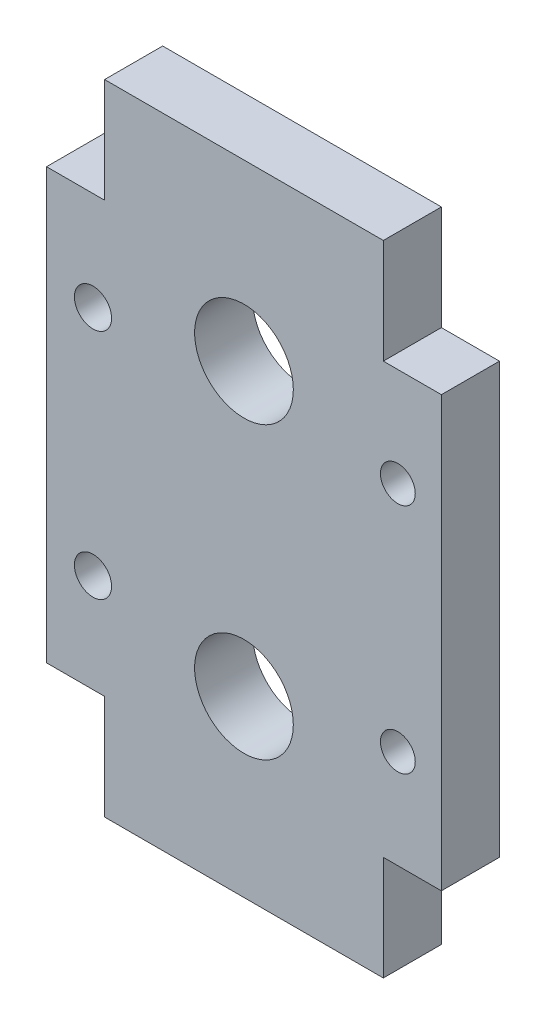
from build123d import *

# Parameters (mm, degrees)
SKETCH1_R           = 1.5
SKETCH1_R_2         = 4.25
SKETCH1_R_3         = 5
SKETCH1_R_4         = 1
BOSS_EXTRUDE2_DEPTH = 5
SKETCH2_W           = 0.5
SKETCH2_H           = 37
BOSS_EXTRUDE3_DEPTH = 5
CUT_EXTRUDE1_DEPTH  = 10
BOSS_EXTRUDE4_DEPTH = 5
SKETCH5_R           = 1.6
CUT_EXTRUDE2_DEPTH  = 10
BOSS_EXTRUDE5_DEPTH = 5
SKETCH7_R           = 1
BOSS_EXTRUDE6_DEPTH = 5
SKETCH8_W           = 5
SKETCH8_H           = 37
CUT_EXTRUDE3_DEPTH  = 33


with BuildPart() as part:
    # Sketch1 → Boss-Extrude2 (new body)
    with BuildSketch(Plane.XY):
        with BuildLine():
            Line((45.25091594, -25.207708346), (50.00091594, -20.457708346))
            Line((50.00091594, -20.457708346), (50.00091594, 24.688738263))
            Line((50.00091594, 24.688738263), (45.147362549, 29.542291654))
            Line((45.147362549, 29.542291654), (26.35446933, 29.542291654))
            Line((26.35446933, 29.542291654), (21.25091594, 24.438738263))
            Line((21.25091594, 24.438738263), (21.25091594, 18.042291654))
            Line((21.25091594, 18.042291654), (20.408095363, 18.042291654))
            Line((20.408095363, 18.042291654), (16.70086026, 18.042291654))
            ThreePointArc((16.70086026, 18.042291654), (12.892426636, 17.542145454), (9.3422674, 16.075624987))
            ThreePointArc((9.3422674, 16.075624987), (2.182128173, 13.100539865), (-5.49908406, 12.043324729))
            Line((-5.49908406, 12.043324729), (-5.49908406, 12.039085999))
            ThreePointArc((-5.49908406, 12.039085999), (-15.49908406, 2.292291654), (-5.49908406, -7.454502691))
            Line((-5.49908406, -7.454502691), (-5.49908406, -7.458741422))
            ThreePointArc((-5.49908406, -7.458741422), (2.182128173, -8.515956557), (9.3422674, -11.491041679))
            ThreePointArc((9.3422674, -11.491041679), (12.892426636, -12.957562146), (16.70086026, -13.457708346))
            Line((16.70086026, -13.457708346), (20.408095363, -13.457708346))
            Line((20.408095363, -13.457708346), (21.25091594, -13.457708346))
            Line((21.25091594, -13.457708346), (21.25091594, -20.207708346))
            Line((21.25091594, -20.207708346), (26.25091594, -25.207708346))
            Line((26.25091594, -25.207708346), (45.25091594, -25.207708346))
        make_face()
        with Locations((46.75091594, -7.707708346)):
            Circle(SKETCH1_R, mode=Mode.SUBTRACT)
        with Locations((46.75091594, 12.292291654)):
            Circle(SKETCH1_R, mode=Mode.SUBTRACT)
        with Locations((33.50091594, 14.792291654)):
            Circle(SKETCH1_R_2, mode=Mode.SUBTRACT)
        with Locations((33.50091594, -10.207708346)):
            Circle(SKETCH1_R_2, mode=Mode.SUBTRACT)
        with Locations((19.25091594, 12.292291654)):
            Circle(SKETCH1_R, mode=Mode.SUBTRACT)
        with Locations((19.25091594, -7.707708346)):
            Circle(SKETCH1_R, mode=Mode.SUBTRACT)
        with Locations((-5.74908406, 2.292291654)):
            Circle(SKETCH1_R_3, mode=Mode.SUBTRACT)
        with Locations((1.25091594, 2.354746229)):
            Circle(SKETCH1_R_4, mode=Mode.SUBTRACT)
        with Locations((-5.686629485, -4.707708346)):
            Circle(SKETCH1_R_4, mode=Mode.SUBTRACT)
        with Locations((-12.74908406, 2.229837079)):
            Circle(SKETCH1_R_4, mode=Mode.SUBTRACT)
        with Locations((-5.811538636, 9.292291654)):
            Circle(SKETCH1_R_4, mode=Mode.SUBTRACT)
    extrude(amount=BOSS_EXTRUDE2_DEPTH)

    # Sketch2 → Boss-Extrude3 (add)
    with BuildSketch(Plane(origin=(0, 0, 0), x_dir=(-1, 0, 0), z_dir=(0, 0, -1))):
        Polygon((-26.25091594, -25.207708346), (-21.50091594, -25.207708346), (-21.50091594, -20.457708346), align=None)
        Polygon((-45.25091594, -25.207708346), (-45.50091594, -25.207708346), (-45.50091594, -24.957708346), align=None)
        Polygon((-45.50091594, 29.188738263), (-45.50091594, 29.792291654), (-21.50091594, 29.792291654), (-21.50091594, 24.688738263), (-26.35446933, 29.542291654), (-45.147362549, 29.542291654), align=None)
        with Locations((-50.25091594, 2.292291654)):
            Rectangle(SKETCH2_W, SKETCH2_H)
    extrude(amount=-BOSS_EXTRUDE3_DEPTH)

    # Sketch3 → Cut-Extrude1 (cut)
    with BuildSketch(Plane(origin=(0, 0, 0), x_dir=(-1, 0, 0), z_dir=(0, 0, -1))):
        Polygon((-50.00091594, -16.207708346), (-45.50091594, -16.207708346), (-45.50091594, -25.207708346), (-50.00091594, -20.457708346), align=None)
        Polygon((-50.50091594, 20.792291654), (-45.50091594, 20.792291654), (-45.50091594, 29.188738263), (-50.00091594, 24.688738263), align=None)
        Polygon((-21.50091594, -16.207708346), (-21.50091594, -20.457708346), (-21.25091594, -20.207708346), (-21.25091594, -16.207708346), align=None)
        Polygon((-21.50091594, 20.792291654), (-21.25091594, 20.792291654), (-21.25091594, 24.438738263), (-21.50091594, 24.688738263), align=None)
    extrude(amount=-CUT_EXTRUDE1_DEPTH, mode=Mode.SUBTRACT)

    # Sketch4 → Boss-Extrude4 (add)
    with BuildSketch(Plane(origin=(0, 0, 0), x_dir=(-1, 0, 0), z_dir=(0, 0, -1))):
        with BuildLine():
            Line((-21.25091594, 20.792291654), (-16.50091594, 20.792291654))
            Line((-16.50091594, 20.792291654), (-16.50091594, 18.040936414))
            ThreePointArc((-16.50091594, 18.040936414), (-16.600885803, 18.04195284), (-16.70086026, 18.042291654))
            Line((-16.70086026, 18.042291654), (-21.25091594, 18.042291654))
            Line((-21.25091594, 18.042291654), (-21.25091594, 20.792291654))
        make_face()
        with BuildLine():
            Line((-16.50091594, -13.456353106), (-16.50091594, -16.207708346))
            Line((-16.50091594, -16.207708346), (-21.25091594, -16.207708346))
            Line((-21.25091594, -16.207708346), (-21.25091594, -13.457708346))
            Line((-21.25091594, -13.457708346), (-16.70086026, -13.457708346))
            ThreePointArc((-16.70086026, -13.457708346), (-16.600885803, -13.457369532), (-16.50091594, -13.456353106))
        make_face()
    extrude(amount=-BOSS_EXTRUDE4_DEPTH)

    # Sketch5 → Cut-Extrude2 (cut)
    with BuildSketch(Plane.XY.offset(5)):
        with Locations((20.50091594, -7.707708346)):
            Circle(SKETCH5_R)
        with Locations((20.50091594, 12.292291654)):
            Circle(SKETCH5_R)
    extrude(amount=-CUT_EXTRUDE2_DEPTH, mode=Mode.SUBTRACT)

    # Sketch6 → Boss-Extrude5 (add)
    with BuildSketch(Plane.XY.offset(5)):
        with BuildLine():
            ThreePointArc((19.75191594, -6.293848735), (18.90091594, -7.707708346), (19.75191594, -9.121567957))
            ThreePointArc((19.75191594, -9.121567957), (17.75091594, -7.707708346), (19.75191594, -6.293848735))
        make_face()
        with BuildLine():
            ThreePointArc((19.75191594, 13.706151265), (18.90091594, 12.292291654), (19.75191594, 10.878432043))
            ThreePointArc((19.75191594, 10.878432043), (17.75091594, 12.292291654), (19.75191594, 13.706151265))
        make_face()
    extrude(amount=-BOSS_EXTRUDE5_DEPTH)

    # Sketch7 → Boss-Extrude6 (add)
    with BuildSketch(Plane(origin=(0, 0, 0), x_dir=(-1, 0, 0), z_dir=(0, 0, -1))):
        with Locations((-1.25091594, 2.354746229)):
            Circle(SKETCH7_R)
        with Locations((12.74908406, 2.229837079)):
            Circle(SKETCH7_R)
    extrude(amount=-BOSS_EXTRUDE6_DEPTH)

    # Sketch8 → Cut-Extrude3 (cut, through all)
    with BuildSketch(Plane.ZY.offset(-16.50091594)):
        with Locations((2.5, 2.292291654)):
            Rectangle(SKETCH8_W, SKETCH8_H)
    extrude(amount=CUT_EXTRUDE3_DEPTH, mode=Mode.SUBTRACT)


solid = part.part
